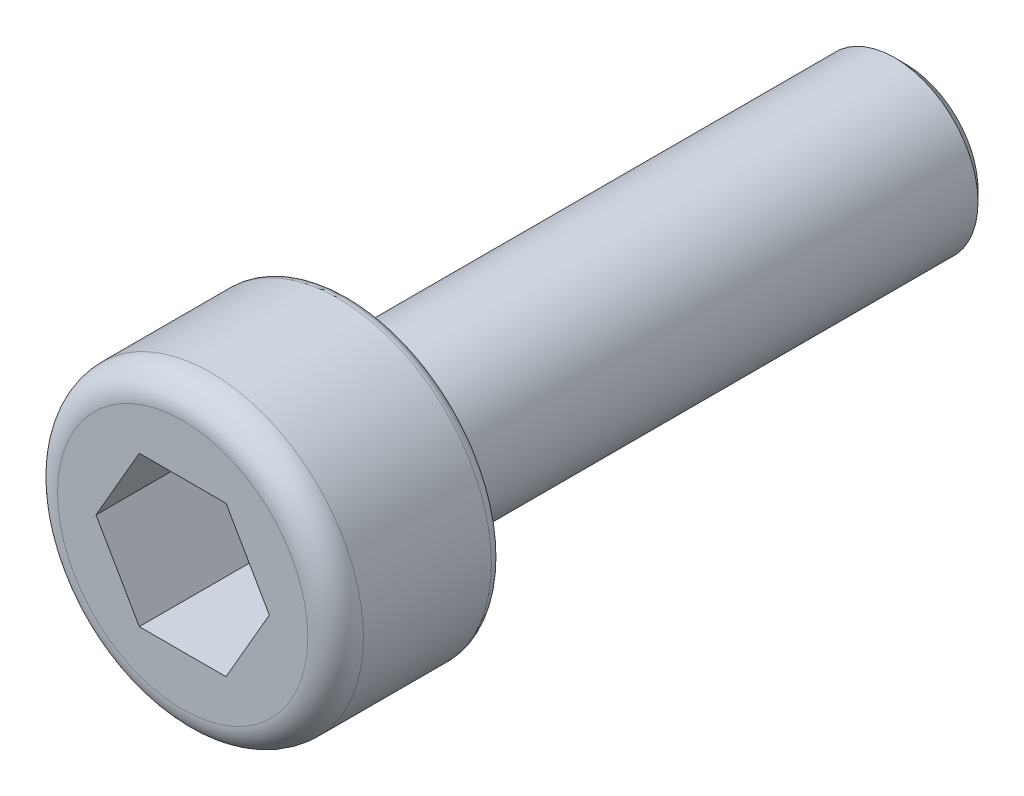
from build123d import *

# Parameters (mm, degrees)
SKETCH_1_R          = 2.75
EXTRUDE_1_DEPTH     = 3
FILLET_1_R          = 0.5
CUT_EXTRUDE_1_DEPTH = 2
SKETCH_3_R          = 1.5
EXTRUDE_2_DEPTH     = 10
CHAMFER_1_SIZE      = 0.2
FILLET_2_R          = 0.2


with BuildPart() as part:
    # 草图1 → 凸台-拉伸1 (new body)
    with BuildSketch(Plane.XY):
        Circle(SKETCH_1_R)
    extrude(amount=EXTRUDE_1_DEPTH)

    # 圆角1
    fillet_1_edges = [part.edges().sort_by_distance(p)[0] for p in [
        (-2.75, 0, 3),
    ]]
    fillet(fillet_1_edges, radius=FILLET_1_R)

    # 草图2 → 切除-拉伸1 (cut)
    with BuildSketch(Plane.XY.offset(3)):
        Polygon((1.558845727, 0), (0.779422863, 1.35), (-0.779422863, 1.35), (-1.558845727, 0), (-0.779422863, -1.35), (0.779422863, -1.35), align=None)
    extrude(amount=-CUT_EXTRUDE_1_DEPTH, mode=Mode.SUBTRACT)

    # 草图3 → 凸台-拉伸2 (add)
    with BuildSketch(Plane(origin=(0, 0, 0), x_dir=(-1, 0, 0), z_dir=(0, 0, -1))):
        Circle(SKETCH_3_R)
    extrude(amount=EXTRUDE_2_DEPTH)

    # 倒角1
    chamfer_1_edges = [part.edges().sort_by_distance(p)[0] for p in [
        (1.5, 0, -10),
    ]]
    chamfer(chamfer_1_edges, length=CHAMFER_1_SIZE)

    # 圆角2
    fillet_2_edges = [part.edges().sort_by_distance(p)[0] for p in [
        (-2.75, 0, 0),
    ]]
    fillet(fillet_2_edges, radius=FILLET_2_R)


solid = part.part
